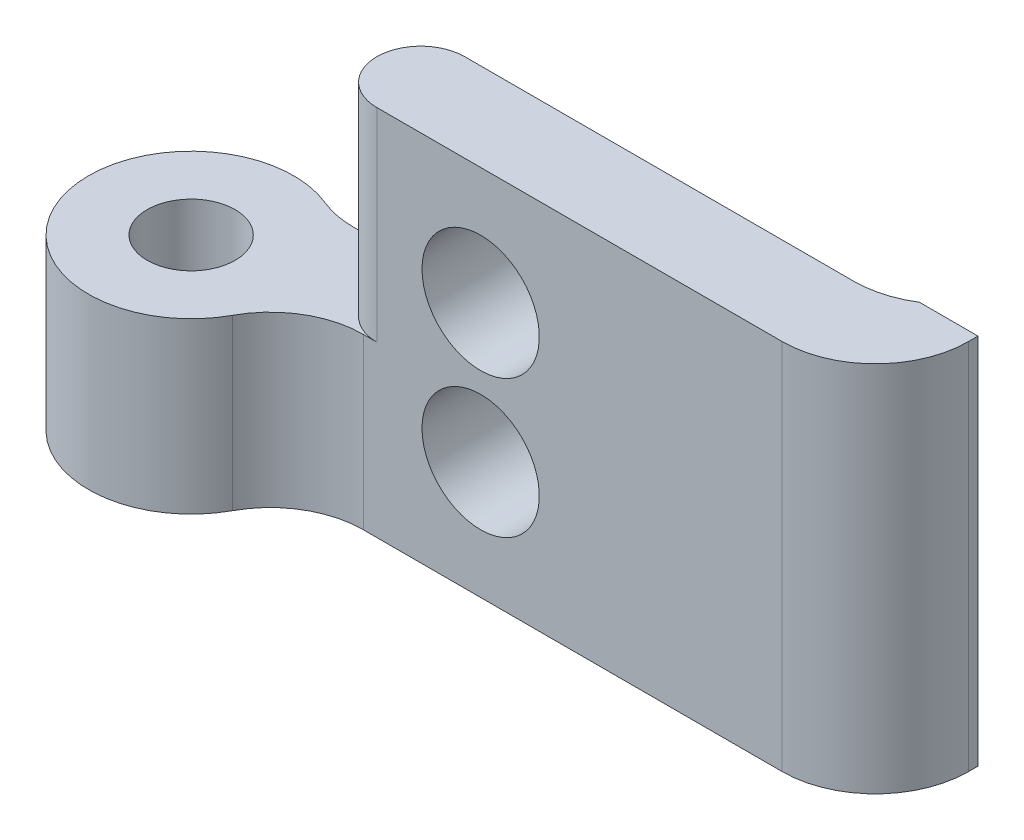
from build123d import *

# Parameters (mm, degrees)
SKETCH1_R           = 3.5
BOSS_EXTRUDE1_DEPTH = 12.7
CUT_EXTRUDE1_START  = -6.93
CUT_EXTRUDE1_DEPTH  = 6.93
SKETCH3_R           = 1.5
CUT_EXTRUDE2_DEPTH  = 6.77
SKETCH4_W           = 2
SKETCH4_H           = 0.5
BOSS_EXTRUDE2_DEPTH = 12.7
FILLET1_R           = 3.175
SKETCH5_R           = 2
CUT_EXTRUDE3_DEPTH  = 10
SKETCH6_R           = 1.585
CUT_EXTRUDE4_DEPTH  = 1.5


with BuildPart() as part:
    # Sketch1 → Boss-Extrude1 (new body)
    with BuildSketch(Plane(origin=(0, 0, 0), x_dir=(1, 0, 0), z_dir=(0, 1, 0))):
        with Locations((-22.063770306, 11.23554707)):
            Circle(SKETCH1_R)
        with BuildLine():
            ThreePointArc((-20.260994668, 14.23554707), (-19.017484475, 12.958957246), (-18.563770306, 11.23554707))
            Line((-18.563770306, 11.23554707), (1.266442488, 11.23554707))
            Line((1.266442488, 11.23554707), (1.266442488, 14.23554707))
            Line((1.266442488, 14.23554707), (-20.260994668, 14.23554707))
        make_face()
    extrude(amount=BOSS_EXTRUDE1_DEPTH)

    # Sketch2 → Cut-Extrude1 (cut)
    with BuildSketch(Plane(origin=(0, 12.7, 0), x_dir=(1, 0, 0), z_dir=(0, 1, 0)).offset(CUT_EXTRUDE1_START)):
        with BuildLine():
            Line((-18.563770306, 11.23554707), (-15.733557512, 11.23554707))
            ThreePointArc((-15.733557512, 11.23554707), (-17.233557512, 12.73554707), (-15.733557512, 14.23554707))
            Line((-15.733557512, 14.23554707), (-20.260994668, 14.23554707))
            ThreePointArc((-20.260994668, 14.23554707), (-25.110056137, 9.512136894), (-18.563770306, 11.23554707))
        make_face()
    extrude(amount=CUT_EXTRUDE1_DEPTH, mode=Mode.SUBTRACT)

    # Sketch3 → Cut-Extrude2 (cut, through all)
    with BuildSketch(Plane(origin=(0, 5.77, 0), x_dir=(1, 0, 0), z_dir=(0, 1, 0))):
        with Locations(Location((-22.063770306, 11.23554707, 0), (0, 0, 270))):  # turned: the seam where the file's is
            Circle(SKETCH3_R)
    extrude(amount=-CUT_EXTRUDE2_DEPTH, mode=Mode.SUBTRACT)

    # Sketch4 → Boss-Extrude2 (add)
    with BuildSketch(Plane(origin=(0, 12.7, 0), x_dir=(1, 0, 0), z_dir=(0, 1, 0))):
        with Locations((0.266442488, 14.48554707)):
            Rectangle(SKETCH4_W, SKETCH4_H)
        with BuildLine():
            Line((-2.472810226, 14.23554707), (-0.733557512, 14.23554707))
            Line((-0.733557512, 14.23554707), (-0.733557512, 14.73554707))
            ThreePointArc((-0.733557512, 14.73554707), (-1.567962172, 14.363028206), (-2.472810226, 14.23554707))
        make_face()
    extrude(amount=-BOSS_EXTRUDE2_DEPTH)

    # Fillet1
    fillet1_edges = [part.edges().sort_by_distance(p)[0] for p in [
        (-20.260994668, 2.885, -14.23554707),
        (-18.563770306, 2.885, -11.23554707),
        (1.266442488, 6.35, -11.23554707),
    ]]
    fillet(fillet1_edges, radius=FILLET1_R)

    # Sketch5 → Cut-Extrude3 (cut)
    with BuildSketch(Plane(origin=(0, 0, -14.23554707), x_dir=(-1, 0, 0), z_dir=(0, 0, -1))):
        with Locations((12.192228771, 8.7)):
            Circle(SKETCH5_R)
        with Locations((12.192228771, 4)):
            Circle(SKETCH5_R)
    extrude(amount=-CUT_EXTRUDE3_DEPTH, mode=Mode.SUBTRACT)

    # Sketch6 → Cut-Extrude4 (cut)
    with BuildSketch(Plane(origin=(0, 0, -14.23554707), x_dir=(-1, 0, 0), z_dir=(0, 0, -1))):
        with Locations((4.733557512, 6.35)):
            Circle(SKETCH6_R)
    extrude(amount=-CUT_EXTRUDE4_DEPTH, mode=Mode.SUBTRACT)


solid = part.part
